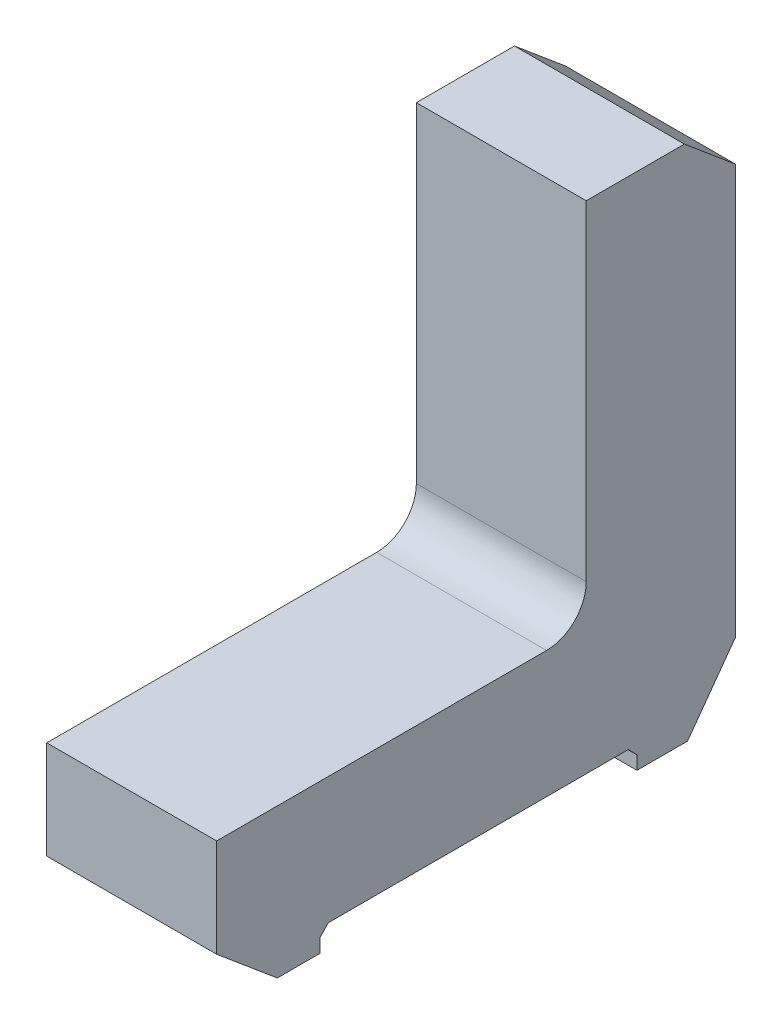
from build123d import *

# Parameters (mm, degrees)
BOSS_EXTRUDE1_DEPTH = 57
CUT_EXTRUDE1_DEPTH  = 58


with BuildPart() as part:
    # Sketch2 → Boss-Extrude1 (new body)
    with BuildSketch(Plane(origin=(0, 0, 0), x_dir=(0, 0, -1), z_dir=(1, 0, 0))):
        with BuildLine():
            Line((-110.680525015, 0), (-110.680525015, -32.921204516))
            Line((-110.680525015, -32.921204516), (-90.326809139, -50))
            Line((-90.326809139, -50), (47.311208732, -50))
            Line((47.311208732, -50), (63.319474985, -27.968828863))
            Line((63.319474985, -27.968828863), (63.319474985, 109.669189008))
            Line((63.319474985, 109.669189008), (46.240679501, 124))
            Line((46.240679501, 124), (13.319474985, 124))
            Line((13.319474985, 124), (13.319474985, 13.319474985))
            ThreePointArc((13.319474985, 13.319474985), (9.418291084, 3.901183901), (0, 0))
            Line((0, 0), (-110.680525015, 0))
        make_face()
    extrude(amount=BOSS_EXTRUDE1_DEPTH)

    # Sketch3 → Cut-Extrude1 (cut, through all)
    with BuildSketch(Plane(origin=(57, 0, 0), x_dir=(0, 0, -1), z_dir=(1, 0, 0))):
        Polygon((-76.075907073, -45.5), (-76.075907073, -50), (30.330747693, -50), (30.330747693, -45.5), (27.461329109, -42.5), (-73.206488489, -42.5), align=None)
    extrude(amount=-CUT_EXTRUDE1_DEPTH, mode=Mode.SUBTRACT)


solid = part.part
